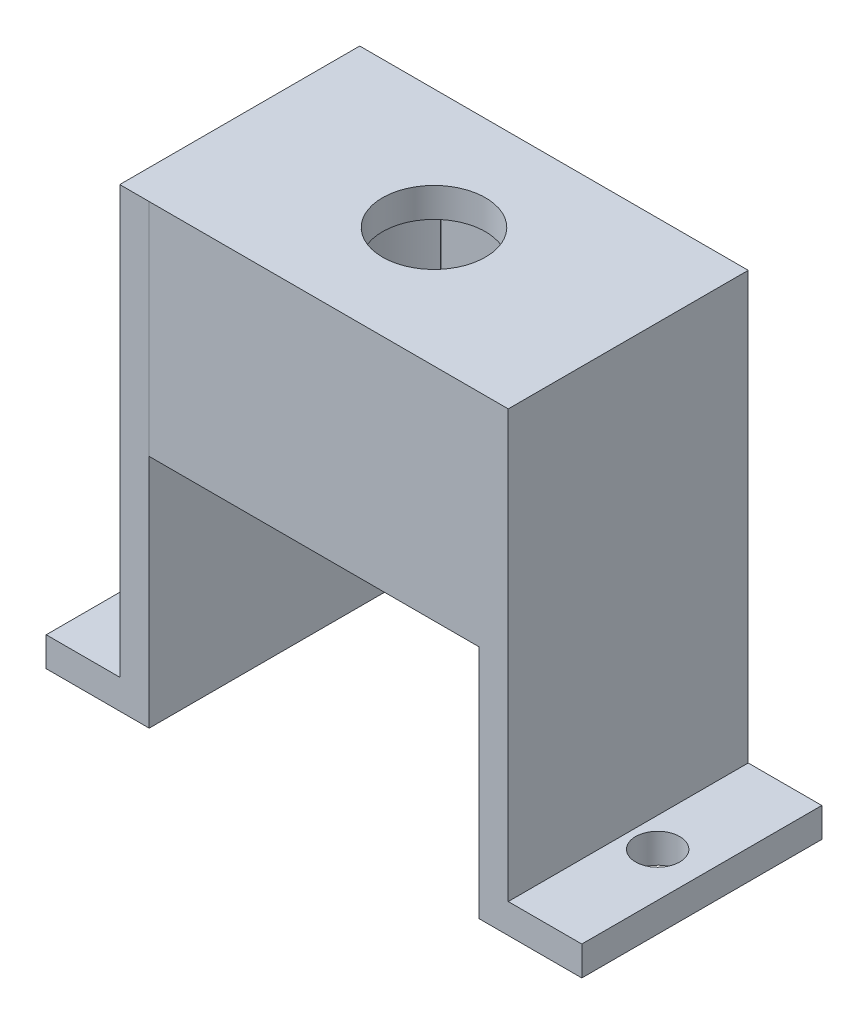
from build123d import *

# Parameters (mm, degrees)
Y_KSEKLIK_EKSTR_ZYON1_DEPTH = 12
Y_KSEKLIK_EKSTR_ZYON3_DEPTH = 15
KES_EKSTR_ZYON2_DEPTH       = 10
IZIM7_R                     = 3.5
KES_EKSTR_ZYON3_DEPTH       = 10
IZIM9_W                     = 16.31
IZIM9_H                     = 31
Y_KSEKLIK_EKSTR_ZYON4_DEPTH = 2
IZIM11_W                    = 16.312144578
IZIM11_H                    = 31
Y_KSEKLIK_EKSTR_ZYON5_DEPTH = 2
IZIM12_W                    = 16.312144578
IZIM12_H                    = 2
Y_KSEKLIK_EKSTR_ZYON6_DEPTH = 5
IZIM13_W                    = 16.31
IZIM13_H                    = 2
Y_KSEKLIK_EKSTR_ZYON7_DEPTH = 5
IZIM16_R                    = 1.5
KES_EKSTR_ZYON4_DEPTH       = 5


with BuildPart() as part:
    # Çizim1 → Yükseklik-Ekstrüzyon1 (new body)
    with BuildSketch(Plane(origin=(0, 0, 0), x_dir=(1, 0, 0), z_dir=(0, 1, 0))):
        with BuildLine():
            Line((-10.273080285, 9.233441174), (-24.270017386, 9.23050626))
            ThreePointArc((-24.270017386, 9.23050626), (-27.573247243, 1.740187513), (-24.270017386, -5.750131234))
            ThreePointArc((-24.270017386, -5.750131234), (-24.266862702, -5.754522055), (-24.265747955, -5.759812487))
            Line((-24.265747955, -5.759812487), (-10.280448773, -5.759812487))
            ThreePointArc((-10.280448773, -5.759812487), (-10.279708775, -5.756150024), (-10.277604879, -5.753062168))
            ThreePointArc((-10.277604879, -5.753062168), (-7.119784217, 1.739236804), (-10.273080285, 9.233441174))
        make_face()
    extrude(amount=Y_KSEKLIK_EKSTR_ZYON1_DEPTH)

    # Çizim2 → Yükseklik-Ekstrüzyon3 (add)
    with BuildSketch(Plane(origin=(0, 12, 0), x_dir=(1, 0, 0), z_dir=(0, 1, 0))):
        Polygon((-28.472879545, -6.371596623), (-24.972879545, -6.371596623), (-6.065973504, -6.371596623), (-6.065973504, 9.940547955), (-9.565973504, 9.940547955), (-28.472879545, 9.940547955), align=None)
        with BuildLine():
            ThreePointArc((-10.277604879, -5.753062168), (-10.279708775, -5.756150024), (-10.280448773, -5.759812487))
            Line((-10.280448773, -5.759812487), (-24.265747955, -5.759812487))
            ThreePointArc((-24.265747955, -5.759812487), (-24.266862702, -5.754522055), (-24.270017386, -5.750131234))
            ThreePointArc((-24.270017386, -5.750131234), (-27.573247243, 1.740187513), (-24.270017386, 9.23050626))
            Line((-24.270017386, 9.23050626), (-10.273080285, 9.233441174))
            ThreePointArc((-10.273080285, 9.233441174), (-7.119784217, 1.739236804), (-10.277604879, -5.753062168))
        make_face(mode=Mode.SUBTRACT)
    extrude(amount=-Y_KSEKLIK_EKSTR_ZYON3_DEPTH)

    # Çizim5 → Kes-Ekstrüzyon2 (cut)
    with BuildSketch(Plane(origin=(0, 0, 0), x_dir=(1, 0, 0), z_dir=(0, 1, 0))):
        with BuildLine():
            ThreePointArc((-24.253497742, -5.732043117), (-24.24760022, -5.74025453), (-24.24552089, -5.750148186))
            Line((-24.24552089, -5.750148186), (-10.281129786, -5.759812016))
            ThreePointArc((-10.281129786, -5.759812016), (-10.28107446, -5.75954361), (-10.280917812, -5.759318746))
            ThreePointArc((-10.280917812, -5.759318746), (-7.055942633, 1.738860839), (-10.261152425, 9.245510703))
            ThreePointArc((-10.261152425, 9.245510703), (-10.261308072, 9.245735025), (-10.261363099, 9.246002453))
            Line((-10.261363099, 9.246002453), (-24.245520899, 9.230533357))
            ThreePointArc((-24.245520899, 9.230533357), (-24.247598176, 9.220634198), (-24.253497742, 9.212418143))
            ThreePointArc((-24.253497742, 9.212418143), (-27.548750741, 1.740187513), (-24.253497742, -5.732043117))
        make_face()
    extrude(amount=KES_EKSTR_ZYON2_DEPTH, mode=Mode.SUBTRACT)

    # Çizim7 → Kes-Ekstrüzyon3 (cut)
    with BuildSketch(Plane(origin=(0, 12, 0), x_dir=(1, 0, 0), z_dir=(0, 1, 0))):
        with Locations((-17.269426524, 1.784475666)):
            Circle(IZIM7_R)
    extrude(amount=-KES_EKSTR_ZYON3_DEPTH, mode=Mode.SUBTRACT)

    # Çizim9 → Yükseklik-Ekstrüzyon4 (add)
    with BuildSketch(Plane.ZY.offset(28.472879545)):
        with Locations((-1.785547955, -3.5)):
            Rectangle(IZIM9_W, IZIM9_H)
    extrude(amount=Y_KSEKLIK_EKSTR_ZYON4_DEPTH)

    # Çizim11 → Yükseklik-Ekstrüzyon5 (add)
    with BuildSketch(Plane(origin=(-6.065973504, 0, 0), x_dir=(0, 0, -1), z_dir=(1, 0, 0))):
        with Locations((1.784475666, -3.5)):
            Rectangle(IZIM11_W, IZIM11_H)
    extrude(amount=Y_KSEKLIK_EKSTR_ZYON5_DEPTH)

    # Çizim12 → Yükseklik-Ekstrüzyon6 (add)
    with BuildSketch(Plane(origin=(-4.065973504, 0, 0), x_dir=(0, 0, -1), z_dir=(1, 0, 0))):
        with Locations((1.784475666, -18)):
            Rectangle(IZIM12_W, IZIM12_H)
    extrude(amount=Y_KSEKLIK_EKSTR_ZYON6_DEPTH)

    # Çizim13 → Yükseklik-Ekstrüzyon7 (add)
    with BuildSketch(Plane.ZY.offset(30.472879545)):
        with Locations((-1.785547955, -18)):
            Rectangle(IZIM13_W, IZIM13_H)
    extrude(amount=Y_KSEKLIK_EKSTR_ZYON7_DEPTH)

    # Çizim16 → Kes-Ekstrüzyon4 (cut)
    with BuildSketch(Plane.XZ.offset(19)):
        with Locations((-32.472879545, -1.785547955)):
            Circle(IZIM16_R)
        with Locations((-2.065973504, -1.784475666)):
            Circle(IZIM16_R)
    extrude(amount=-KES_EKSTR_ZYON4_DEPTH, mode=Mode.SUBTRACT)


solid = part.part
